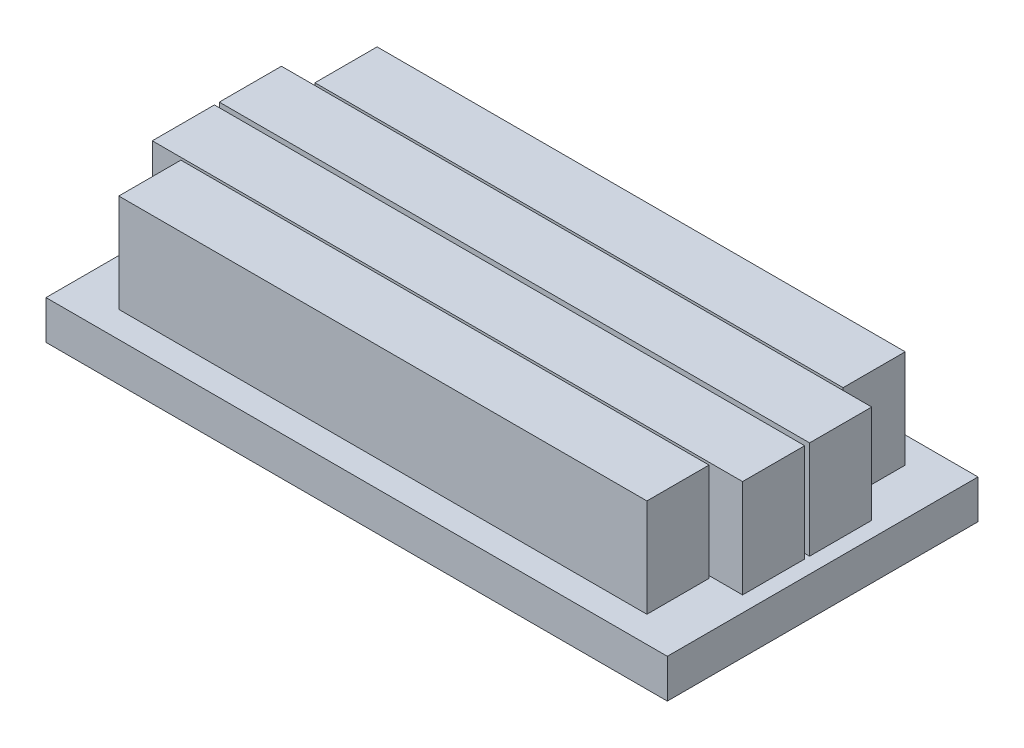
from build123d import *

# Parameters (mm, degrees)
SKETCH1_W           = 25.4
SKETCH1_H           = 12.7
BOSS_EXTRUDE1_DEPTH = 1.5875
SKETCH2_W           = 21.59
SKETCH2_H           = 2.54
SKETCH2_W_2         = 24.13
BOSS_EXTRUDE2_DEPTH = 4.0132


with BuildPart() as part:
    # Sketch1 → Boss-Extrude1 (new body)
    with BuildSketch(Plane(origin=(0, 0, 0), x_dir=(1, 0, 0), z_dir=(0, 1, 0))):
        Rectangle(SKETCH1_W, SKETCH1_H)
    extrude(amount=BOSS_EXTRUDE1_DEPTH)

    # Sketch2 → Boss-Extrude2 (add)
    with BuildSketch(Plane(origin=(0, 1.5875, 0), x_dir=(1, 0, 0), z_dir=(0, 1, 0))):
        with Locations((0, -4.01)):
            Rectangle(SKETCH2_W, SKETCH2_H)
        with Locations((0, -1.37)):
            Rectangle(SKETCH2_W_2, SKETCH2_H)
    boss_extrude2 = extrude(amount=BOSS_EXTRUDE2_DEPTH)

    # Mirror1: Boss-Extrude2 across plane
    add(boss_extrude2.mirror(Plane.XY))


solid = part.part
